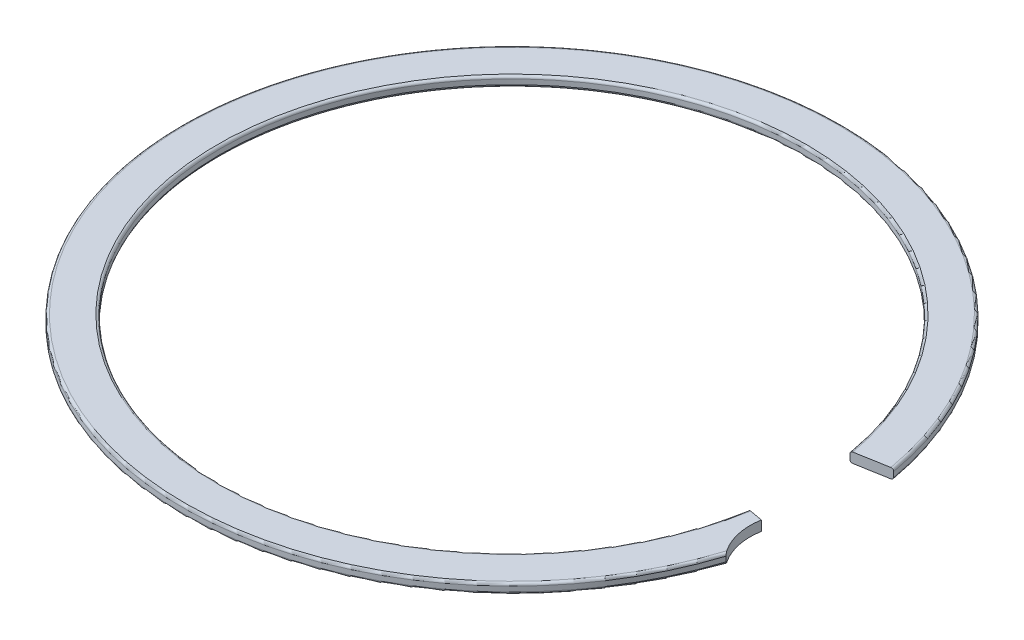
from build123d import *

# Parameters (mm, degrees)
CUT_EXTRUDE1_DEPTH      = 0.7874
CUT_EXTRUDE1_DEPTH_BACK = 0.7874


with BuildPart() as part:
    # Sketch1 → Revolve1 (revolve)
    with BuildSketch(Plane.XY):
        with BuildLine():
            Line((23.1267, 0.19685), (23.1267, -0.19685))
            ThreePointArc((23.1267, -0.19685), (23.18435603, -0.33604397), (23.32355, -0.3937))
            Line((23.32355, -0.3937), (25.92705, -0.3937))
            ThreePointArc((25.92705, -0.3937), (26.06624397, -0.33604397), (26.1239, -0.19685))
            Line((26.1239, -0.19685), (26.1239, 0.19685))
            ThreePointArc((26.1239, 0.19685), (26.06624397, 0.33604397), (25.92705, 0.3937))
            Line((25.92705, 0.3937), (23.32355, 0.3937))
            ThreePointArc((23.32355, 0.3937), (23.18435603, 0.33604397), (23.1267, 0.19685))
        make_face()
    revolve(axis=Axis((0, -1270, 0), (0, 1, 0)))

    # Sketch2 → Cut-Extrude1 (cut, two sides: drawn at the far end of the back side and taken through both)
    with BuildSketch(Plane(origin=(0, 0, 0), x_dir=(1, 0, 0), z_dir=(0, 1, 0)).offset(-CUT_EXTRUDE1_DEPTH_BACK)):
        with BuildLine():
            Line((0, 0), (24.00521421, -4.232766943))
            ThreePointArc((24.00521421, -4.232766943), (24.582954237, -7.45378069), (27.108261822, -9.535014627))
            ThreePointArc((27.108261822, -9.535014627), (28.640097584, -2.349292098), (28.299721185, 4.990004391))
            Line((28.299721185, 4.990004391), (0, 0))
        make_face()
    extrude(amount=CUT_EXTRUDE1_DEPTH + CUT_EXTRUDE1_DEPTH_BACK, mode=Mode.SUBTRACT)


solid = part.part
